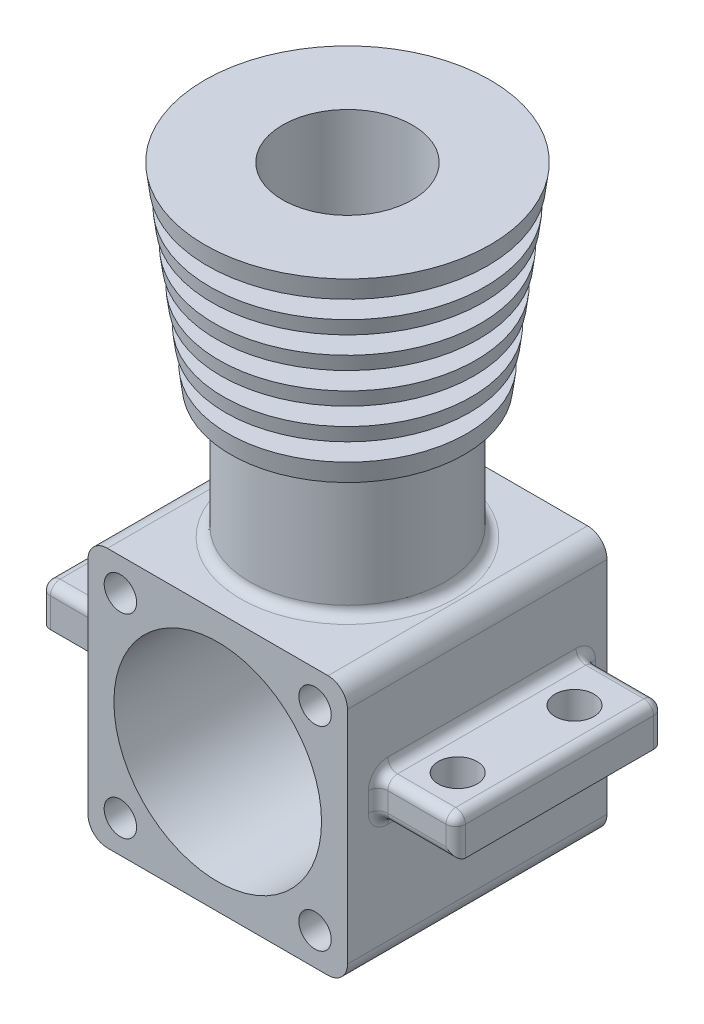
from build123d import *

# Parameters (mm, degrees)
SKETCH1_W           = 40
SKETCH1_H           = 40
SKETCH1_R           = 2.5
SKETCH1_R_2         = 16
BOSS_EXTRUDE1_DEPTH = 20
FILLET2_R           = 3
SKETCH7_W           = 18
SKETCH7_H           = 3
LPATTERN1_COUNT     = 5
LPATTERN1_PITCH     = 5.25
SKETCH8_R           = 10
CUT_EXTRUDE1_DEPTH  = 70
SKETCH10_W          = 12
SKETCH10_H          = 32
SKETCH10_R          = 3
BOSS_EXTRUDE2_DEPTH = 6
FILLET4_R           = 1.5


with BuildPart() as part:
    # Sketch1 → Boss-Extrude1 (new body, symmetric)
    with BuildSketch(Plane.XY):
        with Locations((0.017734769, -0.034630907)):
            Rectangle(SKETCH1_W, SKETCH1_H)
        with Locations((-14.982265231, 14.965369093)):
            Circle(SKETCH1_R, mode=Mode.SUBTRACT)
        with Locations((15.017734769, 14.965369093)):
            Circle(SKETCH1_R, mode=Mode.SUBTRACT)
        with Locations((15.017734769, -15.034630907)):
            Circle(SKETCH1_R, mode=Mode.SUBTRACT)
        with Locations((-14.982265231, -15.034630907)):
            Circle(SKETCH1_R, mode=Mode.SUBTRACT)
        with Locations((0.017734769, -0.034630907)):
            Circle(SKETCH1_R_2, mode=Mode.SUBTRACT)
    extrude(amount=BOSS_EXTRUDE1_DEPTH, both=True)

    # Fillet2
    fillet2_edges = [part.edges().sort_by_distance(p)[0] for p in [
        (20.017734769, -20.034630907, 0),
        (-19.982265231, -20.034630907, 0),
        (-19.982265231, 19.965369093, 0),
        (20.017734769, 19.965369093, 0),
    ]]
    fillet(fillet2_edges, radius=FILLET2_R)

    # Sketch2 → Revolve2 (revolve)
    with BuildSketch(Plane.XY):
        Polygon((0.017734769, 19.965369093), (0.017734769, 69.965369093), (-21.982265231, 69.965369093), (-17.982265231, 39.965369093), (-14.982265231, 39.965369093), (-14.982265231, 19.965369093), align=None)
    revolve(axis=Axis((0.017734769, 19.965369093, 0), (0, 1, 0)))

    # Sketch7 → Cut-Revolve3 (revolve, cut)
    with BuildSketch(Plane.XY):
        with Locations((-20.982265231, 44.465369093)):
            Rectangle(SKETCH7_W, SKETCH7_H)
    cut_revolve3 = revolve(axis=Axis((0.017734769, 42.965369093, 0), (0, 1, 0)), mode=Mode.SUBTRACT)

    # LPattern1: Cut-Revolve3 ×5
    with Locations(*[(0, i * LPATTERN1_PITCH, 0) for i in range(1, LPATTERN1_COUNT)]):
        add(cut_revolve3, mode=Mode.SUBTRACT)

    # Sketch8 → Cut-Extrude1 (cut)
    with BuildSketch(Plane(origin=(0, 69.965369093, 0), x_dir=(1, 0, 0), z_dir=(0, 1, 0))):
        with Locations((0.017734769, 0)):
            Circle(SKETCH8_R)
    extrude(amount=-CUT_EXTRUDE1_DEPTH, mode=Mode.SUBTRACT)

    # Sketch10 → Boss-Extrude2 (add)
    with BuildSketch(Plane(origin=(0, 0, 0), x_dir=(1, 0, 0), z_dir=(0, 1, 0))):
        with Locations((-25.982265231, 0.712845565)):
            Rectangle(SKETCH10_W, SKETCH10_H)
        with Locations((-26, -9)):
            Circle(SKETCH10_R, mode=Mode.SUBTRACT)
        with Locations((-26, 9)):
            Circle(SKETCH10_R, mode=Mode.SUBTRACT)
    boss_extrude2 = extrude(amount=BOSS_EXTRUDE2_DEPTH)

    # Mirror1: Boss-Extrude2 across plane
    add(boss_extrude2.mirror(Plane(origin=(0, 0, 0), x_dir=(0, 0, 1), z_dir=(1, 0, 0))))

    # Fillet4
    fillet4_edges = [part.edges().sort_by_distance(p)[0] for p in [
        (20.017734769, 0, -0.712845565),
        (20.017734769, 6, -0.712845565),
        (20.017734769, 3, 15.287154435),
        (26, 0, 15.287154435),
        (20.017734769, 3, -16.712845565),
        (31.982265231, 3, 15.287154435),
        (31.982265231, 3, -16.712845565),
        (26, 6, -16.712845565),
        (31.982265231, 6, -0.712845565),
        (26, 6, 15.287154435),
        (15.017734769, 19.965369093, 0),
        (-19.982265231, 6, -0.712845565),
        (-19.982265231, 3, -16.712845565),
        (-31.982265231, 3, -16.712845565),
        (-19.982265231, 3, 15.287154435),
        (-31.982265231, 3, 15.287154435),
        (-25.982265231, 6, -16.712845565),
        (-25.982265231, 6, 15.287154435),
        (-31.982265231, 6, -0.712845565),
    ]]
    fillet(fillet4_edges, radius=FILLET4_R)


solid = part.part
